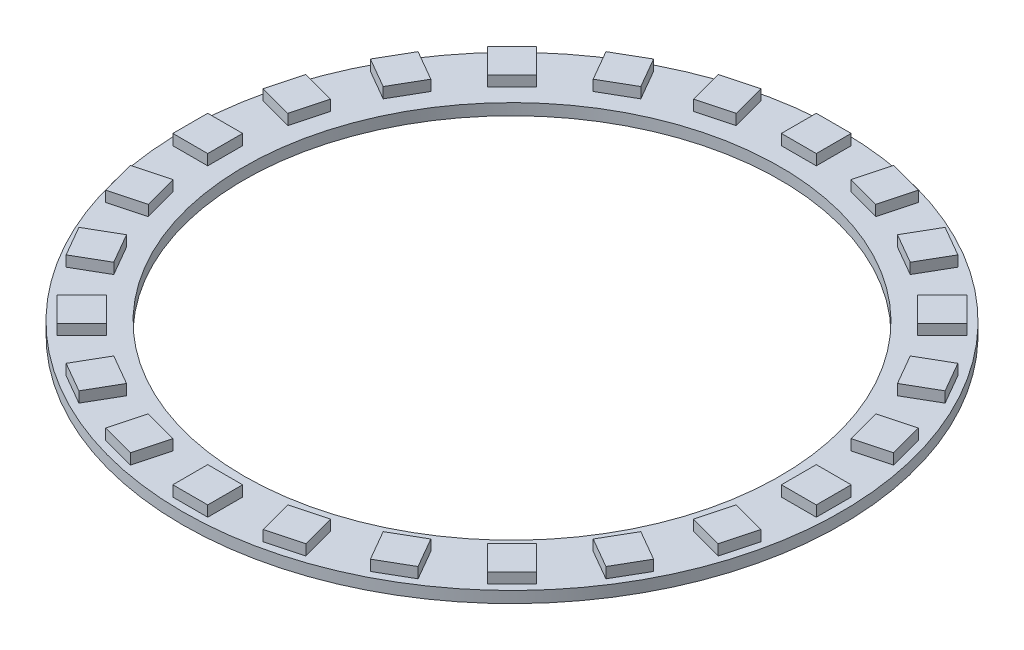
from build123d import *

# Parameters (mm, degrees)
SKETCH_1_R               = 46.3
SKETCH_1_R_2             = 37.65
EXTRUDE_1_DEPTH          = 1.6
SKETCH_2_W               = 4.9
SKETCH_2_H               = 4.9
EXTRUDE_2_DEPTH          = 1.5
PATTERN_CIRCULAR_1_COUNT = 24


with BuildPart() as part:
    # 草图1 → 凸台-拉伸1 (new body)
    with BuildSketch(Plane(origin=(0, 0, 0), x_dir=(1, 0, 0), z_dir=(0, 1, 0))):
        Circle(SKETCH_1_R)
        Circle(SKETCH_1_R_2, mode=Mode.SUBTRACT)
    extrude(amount=EXTRUDE_1_DEPTH)

    # 草图2 → 凸台-拉伸2 (add)
    with BuildSketch(Plane(origin=(0, 1.6, 0), x_dir=(1, 0, 0), z_dir=(0, 1, 0))):
        with Locations((-42.75, 0)):
            Rectangle(SKETCH_2_W, SKETCH_2_H)
    extrude_2 = extrude(amount=EXTRUDE_2_DEPTH)

    # 阵列(圆周)1: 凸台-拉伸2 ×24 about axis
    pattern_circular_1_axis = Axis((0, 0, 0), (0, 1, 0))
    for i in range(1, PATTERN_CIRCULAR_1_COUNT):
        add(extrude_2.rotate(pattern_circular_1_axis, i * 360 / PATTERN_CIRCULAR_1_COUNT))


solid = part.part
